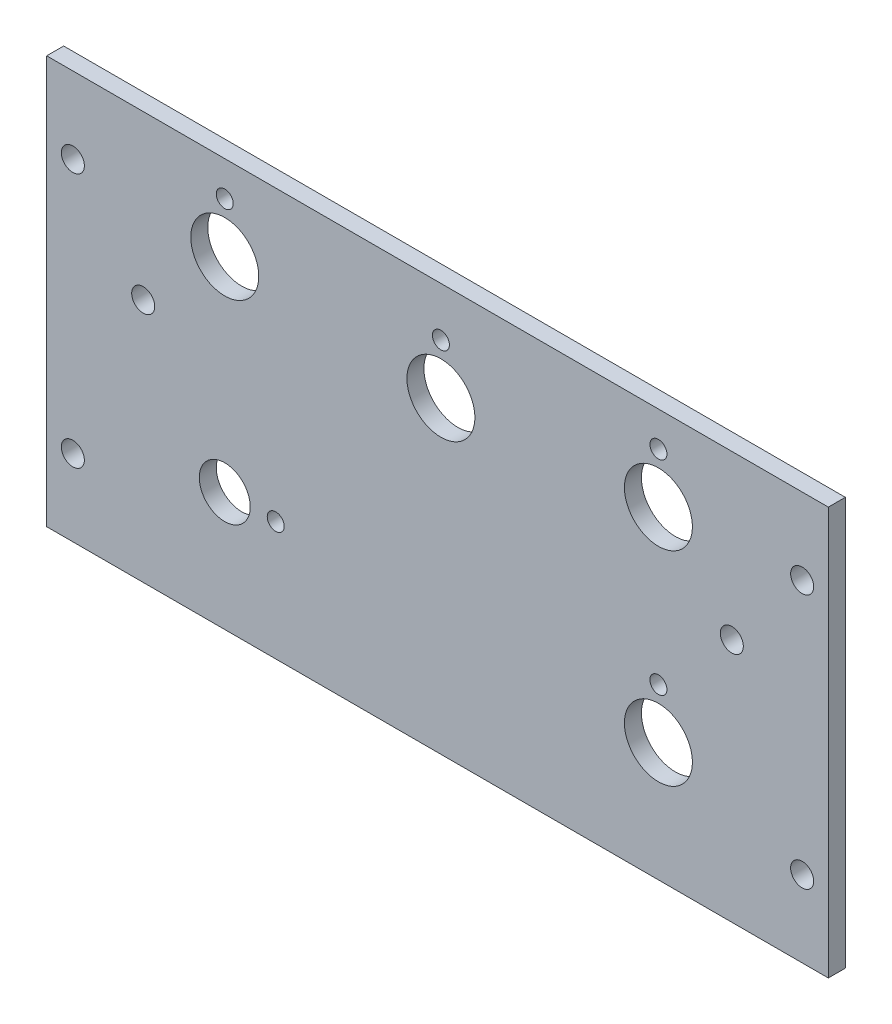
from build123d import *

# Parameters (mm, degrees)
SKETCH1_W                    = 146.05
SKETCH1_H                    = 76.2
BOSS_EXTRUDE1_DEPTH          = 3.175
F_6_CLEARANCE_HOLE1_D        = 4.3053
F_3_8_0_375_DIAMETER_HOLE1_D = 9.525
F_1_2_0_5_DIAMETER_HOLE1_D   = 12.7
F_1_8_0_125_DIAMETER_HOLE1_D = 3.175


with BuildPart() as part:
    # Sketch1 → Boss-Extrude1 (new body)
    with BuildSketch(Plane.XY):
        with Locations((-73.025, 38.1)):
            Rectangle(SKETCH1_W, SKETCH1_H)
    extrude(amount=-BOSS_EXTRUDE1_DEPTH)

    # #6 Clearance Hole1 (through all)
    with Locations(Plane(origin=(0, 0, -3.175), x_dir=(-1, 0, 0), z_dir=(0, 0, -1))):
        with Locations((4.8895, 61.9125), (4.8895, 14.2875), (141.1605, 14.2875), (141.1605, 61.9125), (128.016, 45.72), (18.034, 45.72)):
            Hole(F_6_CLEARANCE_HOLE1_D / 2)

    # 3/8 (0.375) Diameter Hole1 (through all)
    with Locations(Plane(origin=(0, 0, -3.175), x_dir=(-1, 0, 0), z_dir=(0, 0, -1))):
        with Locations((112.776, 22.225)):
            Hole(F_3_8_0_375_DIAMETER_HOLE1_D / 2)

    # 1/2 (0.5) Diameter Hole1 (through all)
    with Locations(Plane(origin=(0, 0, -3.175), x_dir=(-1, 0, 0), z_dir=(0, 0, -1))):
        with Locations((31.75, 60.325), (72.39, 57.658), (112.776, 60.325), (31.75, 22.225)):
            Hole(F_1_2_0_5_DIAMETER_HOLE1_D / 2)

    # 1/8 (0.125) Diameter Hole1 (through all)
    with Locations(Plane(origin=(0, 0, -3.175), x_dir=(-1, 0, 0), z_dir=(0, 0, -1))):
        with Locations((31.75, 69.699492067), (112.776, 69.699492067), (103.251, 22.225), (72.39, 67.032492067), (31.75, 31.599492067)):
            Hole(F_1_8_0_125_DIAMETER_HOLE1_D / 2)


solid = part.part
